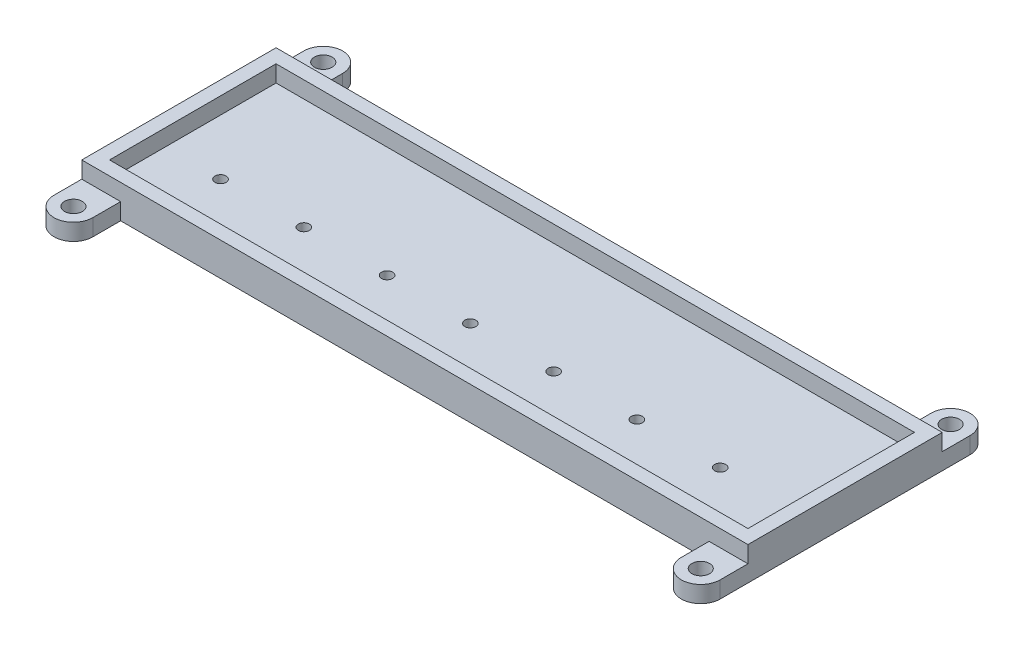
from build123d import *

# Parameters (mm, degrees)
SKETCH1_W               = 115
SKETCH1_H               = 30
BOSS_EXTRUDE1_DEPTH     = 3
SKETCH2_W               = 120
SKETCH2_H               = 35
SKETCH2_W_2             = 115
SKETCH2_H_2             = 30
BOSS_EXTRUDE3_DEPTH     = 6
SKETCH4_R               = 1
CUT_EXTRUDE1_DEPTH      = 4
LPATTERN1_COUNT         = 7
LPATTERN1_PITCH         = 15
SKETCH5_R               = 1.6
BOSS_EXTRUDE4_DEPTH     = 3
MIRROR2_COPY_1_SKETCH_R = 1.6
MIRROR2_COPY_1_DEPTH    = 3


with BuildPart() as part:
    # Sketch1 → Boss-Extrude1 (new body)
    with BuildSketch(Plane(origin=(0, 0, 0), x_dir=(1, 0, 0), z_dir=(0, 1, 0))):
        with Locations((57.5, 15)):
            Rectangle(SKETCH1_W, SKETCH1_H)
    extrude(amount=BOSS_EXTRUDE1_DEPTH)

    # Sketch2 → Boss-Extrude3 (add)
    with BuildSketch(Plane(origin=(0, 0, 0), x_dir=(1, 0, 0), z_dir=(0, 1, 0))):
        with Locations((57.5, 15)):
            Rectangle(SKETCH2_W, SKETCH2_H)
        with Locations((57.5, 15)):
            Rectangle(SKETCH2_W_2, SKETCH2_H_2, mode=Mode.SUBTRACT)
    extrude(amount=BOSS_EXTRUDE3_DEPTH)

    # Sketch4 → Cut-Extrude1 (cut, symmetric)
    with BuildSketch(Plane(origin=(0, 3, 0), x_dir=(1, 0, 0), z_dir=(0, 1, 0))):
        with Locations((10, 10)):
            Circle(SKETCH4_R)
    cut_extrude1 = extrude(amount=CUT_EXTRUDE1_DEPTH, both=True, mode=Mode.SUBTRACT)

    # LPattern1: Cut-Extrude1 ×7
    with Locations(*[(i * LPATTERN1_PITCH, 0, 0) for i in range(1, LPATTERN1_COUNT)]):
        add(cut_extrude1, mode=Mode.SUBTRACT)

    # Sketch5 → Boss-Extrude4 (add)
    with BuildSketch(Plane(origin=(0, 0, 0), x_dir=(1, 0, 0), z_dir=(0, 1, 0))):
        with BuildLine():
            Line((-2.5, -2.5), (-2.5, -7.5))
            ThreePointArc((-2.5, -7.5), (1, -11), (4.5, -7.5))
            Line((4.5, -7.5), (4.5, -2.5))
            Line((4.5, -2.5), (-2.5, -2.5))
        make_face()
        with Locations((1, -7.5)):
            Circle(SKETCH5_R, mode=Mode.SUBTRACT)
    boss_extrude4 = extrude(amount=BOSS_EXTRUDE4_DEPTH)

    # Mirror1: Boss-Extrude4 across plane
    add(boss_extrude4.mirror(Plane.XY.offset(-15)))

    # Mirror2: Boss-Extrude4 across plane
    add(boss_extrude4.mirror(Plane.ZY.offset(-57.5)))

    # Mirror2 copy 1 sketch → Mirror2 copy 1 (add)
    with BuildSketch(Plane(origin=(115, 0, -30), x_dir=(-1, 0, 0), z_dir=(0, 1, 0))):
        with BuildLine():
            Line((-2.5, -2.5), (-2.5, -7.5))
            ThreePointArc((-2.5, -7.5), (1, -11), (4.5, -7.5))
            Line((4.5, -7.5), (4.5, -2.5))
            Line((4.5, -2.5), (-2.5, -2.5))
        make_face()
        with Locations((1, -7.5)):
            Circle(MIRROR2_COPY_1_SKETCH_R, mode=Mode.SUBTRACT)
    extrude(amount=MIRROR2_COPY_1_DEPTH)


solid = part.part
